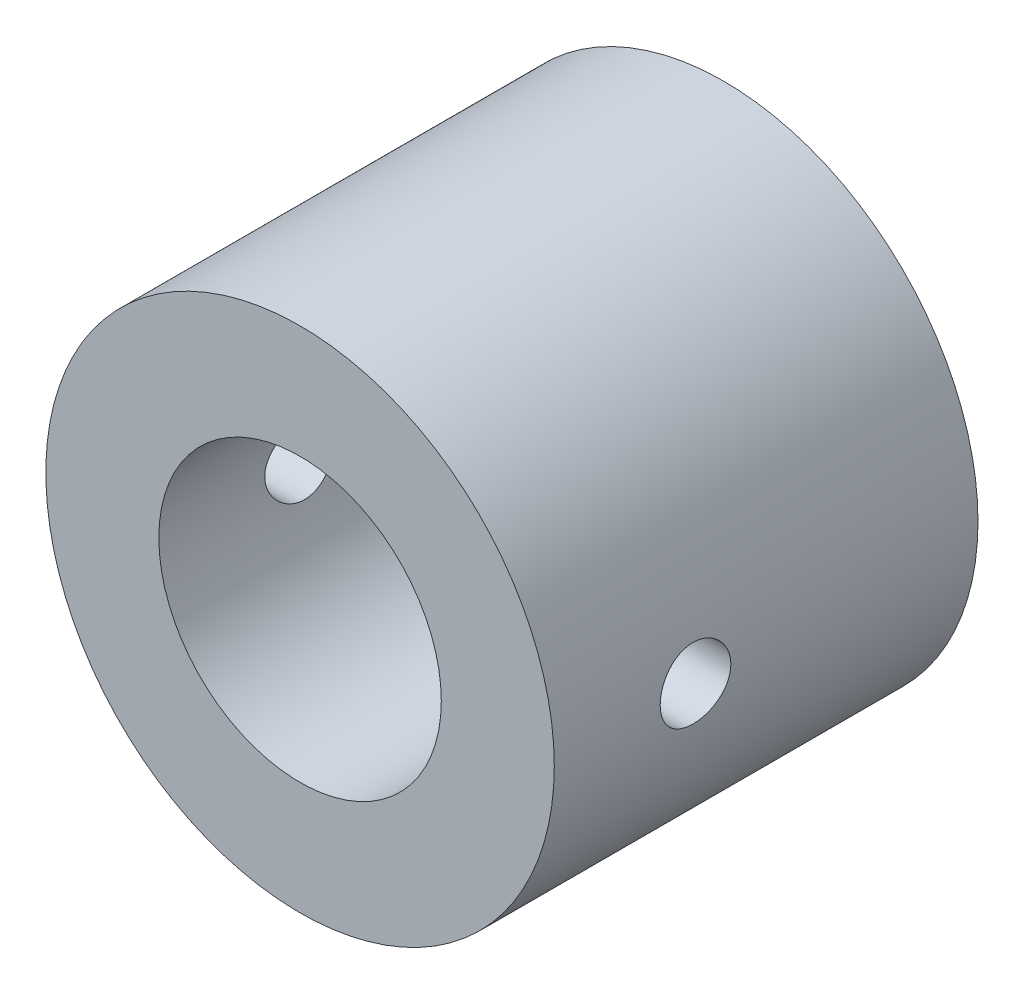
from build123d import *

# Parameters (mm, degrees)
ESQUISSE1_R             = 9
ESQUISSE1_R_2           = 5
BOSS_EXTRU_1_DEPTH      = 15
TROU_TARAUD_M31_D       = 2.5
TROU_TARAUD_M31_DEPTH   = 8.5
TROU_TARAUD_M31_TIP     = 0.751075774
TROU_TARAUD_M32_D       = 2.5
TROU_TARAUD_M32_DEPTH   = 8.5
TROU_TARAUD_M32_TIP     = 0.751075774
ESQUISSE9_R             = 8.1
ENL_V_MAT_EXTRU_1_DEPTH = 1


with BuildPart() as part:
    # Esquisse1 → Boss.-Extru.1 (new body)
    with BuildSketch(Plane.XY):
        Circle(ESQUISSE1_R)
        Circle(ESQUISSE1_R_2, mode=Mode.SUBTRACT)
    extrude(amount=BOSS_EXTRU_1_DEPTH)

    # Trou taraudé M31
    with Locations(Plane(origin=(9, 0, 0), x_dir=(0, 0, -1), z_dir=(1, 0, 0))):
        with Locations((-10, 0)):
            Hole(TROU_TARAUD_M31_D / 2, depth=TROU_TARAUD_M31_DEPTH)
            with Locations((0, 0, -(TROU_TARAUD_M31_DEPTH + TROU_TARAUD_M31_TIP / 2))):  # 118° drill point
                Cone(0, TROU_TARAUD_M31_D / 2, TROU_TARAUD_M31_TIP, mode=Mode.SUBTRACT)

    # Trou taraudé M32
    with Locations(Plane(origin=(-9, 0, 0), x_dir=(0, 0, -1), z_dir=(-1, 0, 0))):
        with Locations((-10, 0)):
            Hole(TROU_TARAUD_M32_D / 2, depth=TROU_TARAUD_M32_DEPTH)
            with Locations((0, 0, -(TROU_TARAUD_M32_DEPTH + TROU_TARAUD_M32_TIP / 2))):  # 118° drill point
                Cone(0, TROU_TARAUD_M32_D / 2, TROU_TARAUD_M32_TIP, mode=Mode.SUBTRACT)

    # Esquisse9 → Enlèv. mat.-Extru.1 (cut)
    with BuildSketch(Plane(origin=(0, 0, 0), x_dir=(-1, 0, 0), z_dir=(0, 0, -1))):
        Circle(ESQUISSE9_R)
    extrude(amount=-ENL_V_MAT_EXTRU_1_DEPTH, mode=Mode.SUBTRACT)


solid = part.part
